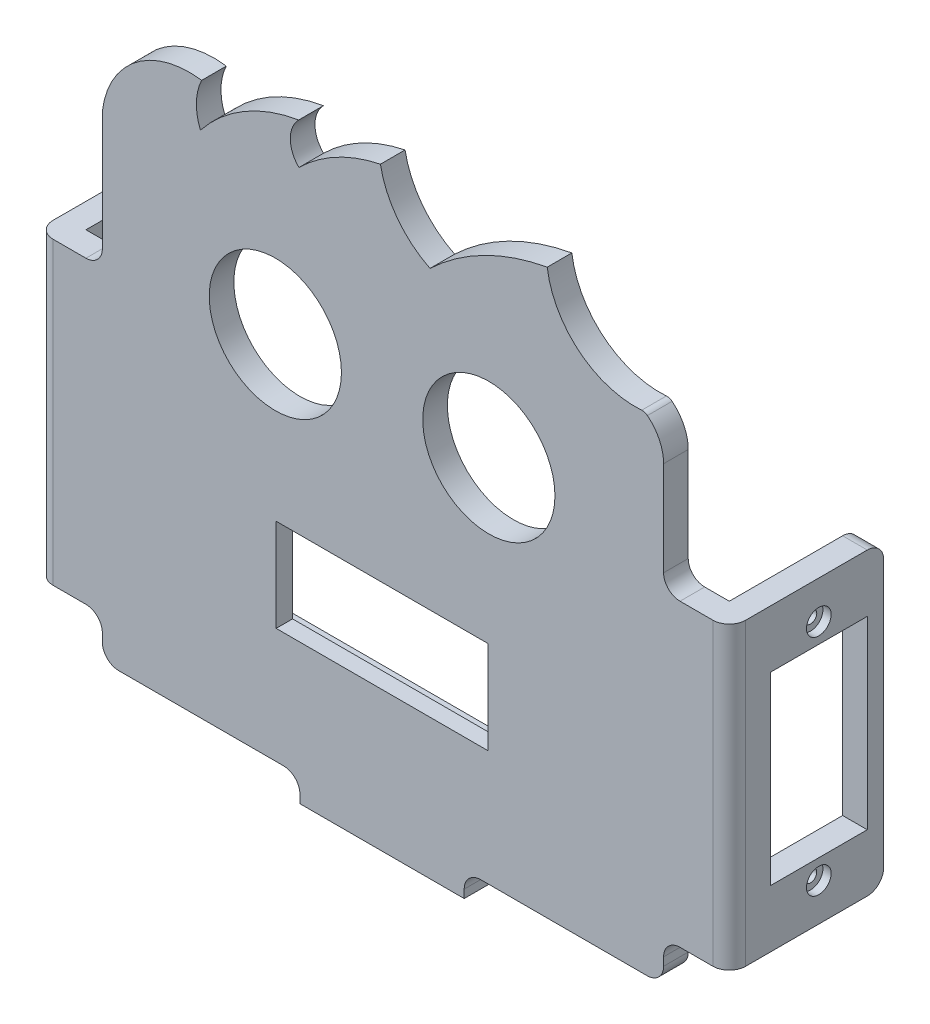
from build123d import *

# Parameters (mm, degrees)
MODEL_R                  = 8.05
MODEL_W                  = 25.8
MODEL_H                  = 11.3
SALIENTE_EXTRUIR1_DEPTH  = 3
CROQUIS2_W               = 38.3
CROQUIS2_H               = 12.1
CORTAR_EXTRUIR1_DEPTH    = 1
CROQUIS3_W               = 3
CROQUIS3_H               = 36.5
SALIENTE_EXTRUIR2_DEPTH  = 15.8
CROQUIS4_R               = 0.75
CROQUIS4_W               = 11.8
CROQUIS4_H               = 22.5
CORTAR_EXTRUIR2_DEPTH    = 3
CROQUIS5_R               = 1.5
CORTAR_EXTRUIR3_DEPTH    = 1
REDONDEO1_R              = 2
REDONDEO1_OF_SIMETR_A1_R = 2
REDONDEO2_R              = 2
CROQUIS6_W               = 20
CROQUIS6_H               = 3
SALIENTE_EXTRUIR3_DEPTH  = 8
CROQUIS7_R               = 1.5
CORTAR_EXTRUIR4_DEPTH    = 3
CROQUIS8_R               = 2.25
CORTAR_EXTRUIR5_DEPTH    = 1
REDONDEO3_R              = 2


with BuildPart() as part:
    # Model → Saliente-Extruir1 (new body)
    with BuildSketch(Plane.XY):
        with BuildLine():
            Line((102.870799912, -11.520997464), (102.870799912, -48.020997464))
            Line((102.870799912, -48.020997464), (96.870799912, -48.020997464))
            ThreePointArc((96.870799912, -48.020997464), (95.456586349, -48.606783901), (94.870799912, -50.020997464))
            Line((94.870799912, -50.020997464), (94.870799912, -51.020997464))
            ThreePointArc((94.870799912, -51.020997464), (94.285013474, -52.435211026), (92.870799912, -53.020997464))
            Line((92.870799912, -53.020997464), (72.589823504, -53.020997464))
            ThreePointArc((72.589823504, -53.020997464), (71.175609941, -53.606783901), (70.589823504, -55.020997464))
            Line((70.589823504, -55.020997464), (70.589823504, -56.021223523))
            Line((70.589823504, -56.021223523), (50.589823504, -56.021223523))
            Line((50.589823504, -56.021223523), (50.589823504, -55.021203031))
            ThreePointArc((50.589823504, -55.021203031), (50.004044311, -53.606996713), (48.589843996, -53.021203031))
            Line((48.589843996, -53.021203031), (28.527119253, -53.020997464))
            ThreePointArc((28.527119253, -53.020997464), (27.112905691, -52.435211026), (26.527119253, -51.020997464))
            Line((26.527119253, -51.020997464), (26.527119253, -50.020997464))
            ThreePointArc((26.527119253, -50.020997464), (25.941332816, -48.606783901), (24.527119253, -48.020997464))
            Line((24.527119253, -48.020997464), (18.527119253, -48.020997464))
            Line((18.527119253, -48.020997464), (18.527119253, -11.520997464))
            Line((18.527119253, -11.520997464), (24.527119253, -11.520997464))
            ThreePointArc((24.527119253, -11.520997464), (25.941332816, -10.935211026), (26.527119253, -9.520997464))
            Line((26.527119253, -9.520997464), (26.527119253, 4.938044993))
            ThreePointArc((26.527119253, 4.938044993), (30.595611796, 12.168478816), (38.618250464, 14.282497178))
            ThreePointArc((38.618250464, 14.282497178), (37.976525569, 11.63682094), (38.471226177, 8.959754465))
            ThreePointArc((38.471226177, 8.959754465), (43.800023098, 13.598439583), (50.438823204, 16.015009344))
            ThreePointArc((50.438823204, 16.015009344), (49.41482724, 13.510261305), (50.461877073, 11.015062492))
            ThreePointArc((50.461877073, 11.015062492), (55.039384462, 14.390193601), (60.387431279, 16.325000863))
            ThreePointArc((60.387431279, 16.325000863), (62.464845981, 11.626325475), (66.424253692, 8.352750544))
            ThreePointArc((66.424253692, 8.352750544), (73.028771683, 13.03256979), (80.697857855, 15.622064598))
            ThreePointArc((80.697857855, 15.622064598), (84.601159243, 8.674615803), (92.204558947, 6.289009084))
            ThreePointArc((92.204558947, 6.289009084), (92.573891536, 6.246895811), (92.902325099, 6.072793877))
            ThreePointArc((92.902325099, 6.072793877), (94.353114302, 4.250236817), (94.870799912, 1.979002536))
            Line((94.870799912, 1.979002536), (94.870799912, -9.520997464))
            ThreePointArc((94.870799912, -9.520997464), (95.456586349, -10.935211026), (96.870799912, -11.520997464))
            Line((96.870799912, -11.520997464), (102.870799912, -11.520997464))
        make_face()
        with Locations((73.589823504, -8.020694487)):
            Circle(MODEL_R, mode=Mode.SUBTRACT)
        with Locations((47.589823504, -8.020694487)):
            Circle(MODEL_R, mode=Mode.SUBTRACT)
        with Locations((60.589823504, -33.326919867)):
            Rectangle(MODEL_W, MODEL_H, mode=Mode.SUBTRACT)
    extrude(amount=SALIENTE_EXTRUIR1_DEPTH)

    # Croquis2 → Cortar-Extruir1 (cut)
    with BuildSketch(Plane(origin=(0, 0, 0), x_dir=(-1, 0, 0), z_dir=(0, 0, -1))):
        with Locations((-61.789823504, -33.326919867)):
            Rectangle(CROQUIS2_W, CROQUIS2_H)
    extrude(amount=-CORTAR_EXTRUIR1_DEPTH, mode=Mode.SUBTRACT)

    # Croquis3 → Saliente-Extruir2 (add)
    with BuildSketch(Plane(origin=(0, 0, 0), x_dir=(-1, 0, 0), z_dir=(0, 0, -1))):
        with Locations((-101.370799912, -29.770997464)):
            Rectangle(CROQUIS3_W, CROQUIS3_H)
    saliente_extruir2 = extrude(amount=SALIENTE_EXTRUIR2_DEPTH)

    # Croquis4 → Cortar-Extruir2 (cut)
    with BuildSketch(Plane(origin=(102.870799912, 0, 0), x_dir=(0, 0, -1), z_dir=(1, 0, 0))):
        with Locations((7.9, -43.420997464)):
            Circle(CROQUIS4_R)
        with Locations((7.9, -16.120997464)):
            Circle(CROQUIS4_R)
        with Locations((7.9, -29.770997464)):
            Rectangle(CROQUIS4_W, CROQUIS4_H)
    cortar_extruir2 = extrude(amount=-CORTAR_EXTRUIR2_DEPTH, mode=Mode.SUBTRACT)

    # Croquis5 → Cortar-Extruir3 (cut)
    with BuildSketch(Plane(origin=(102.870799912, 0, 0), x_dir=(0, 0, -1), z_dir=(1, 0, 0))):
        with Locations((7.9, -16.120997464)):
            Circle(CROQUIS5_R)
        with Locations((7.9, -43.420997464)):
            Circle(CROQUIS5_R)
    cortar_extruir3 = extrude(amount=-CORTAR_EXTRUIR3_DEPTH, mode=Mode.SUBTRACT)

    # Redondeo1
    redondeo1_edges = [part.edges().sort_by_distance(p)[0] for p in [
        (101.370799912, -48.020997464, -15.8),
        (101.370799912, -11.520997464, -15.8),
    ]]
    fillet(redondeo1_edges, radius=REDONDEO1_R)

    # Simetría1: Saliente-Extruir2, Cortar-Extruir2, Cortar-Extruir3 across plane
    add(saliente_extruir2.mirror(Plane(origin=(60.700799912, 0, 0), x_dir=(0, 0, 1), z_dir=(1, 0, 0))))
    add(cortar_extruir2.mirror(Plane(origin=(60.700799912, 0, 0), x_dir=(0, 0, 1), z_dir=(1, 0, 0))), mode=Mode.SUBTRACT)
    add(cortar_extruir3.mirror(Plane(origin=(60.700799912, 0, 0), x_dir=(0, 0, 1), z_dir=(1, 0, 0))), mode=Mode.SUBTRACT)

    # Redondeo1 of Simetría1
    redondeo1_of_simetr_a1_edges = [part.edges().sort_by_distance(p)[0] for p in [
        (20.030799912, -48.020997464, -15.8),
        (20.030799912, -11.520997464, -15.8),
    ]]
    fillet(redondeo1_of_simetr_a1_edges, radius=REDONDEO1_OF_SIMETR_A1_R)

    # Redondeo2
    redondeo2_edges = [part.edges().sort_by_distance(p)[0] for p in [
        (18.527119253, -29.770997464, 3),
        (102.870799912, -29.770997464, 3),
    ]]
    fillet(redondeo2_edges, radius=REDONDEO2_R)

    # Croquis6 → Saliente-Extruir3 (add)
    with BuildSketch(Plane(origin=(0, 0, 0), x_dir=(-1, 0, 0), z_dir=(0, 0, -1))):
        with Locations((-60.589823504, -54.521223523)):
            Rectangle(CROQUIS6_W, CROQUIS6_H)
    extrude(amount=SALIENTE_EXTRUIR3_DEPTH)

    # Croquis7 → Cortar-Extruir4 (cut)
    with BuildSketch(Plane(origin=(0, -53.021223523, 0), x_dir=(1, 0, 0), z_dir=(0, 1, 0))):
        with Locations((66.589823504, 3.5)):
            Circle(CROQUIS7_R)
        with Locations((54.589823504, 3.5)):
            Circle(CROQUIS7_R)
    extrude(amount=-CORTAR_EXTRUIR4_DEPTH, mode=Mode.SUBTRACT)

    # Croquis8 → Cortar-Extruir5 (cut)
    with BuildSketch(Plane(origin=(0, -53.021223523, 0), x_dir=(1, 0, 0), z_dir=(0, 1, 0))):
        with Locations((66.589823504, 3.5)):
            Circle(CROQUIS8_R)
        with Locations((54.589823504, 3.5)):
            Circle(CROQUIS8_R)
    extrude(amount=-CORTAR_EXTRUIR5_DEPTH, mode=Mode.SUBTRACT)

    # Redondeo3
    redondeo3_edges = [part.edges().sort_by_distance(p)[0] for p in [
        (70.589823504, -54.521223523, -8),
        (50.589823504, -54.521223523, -8),
    ]]
    fillet(redondeo3_edges, radius=REDONDEO3_R)


solid = part.part
